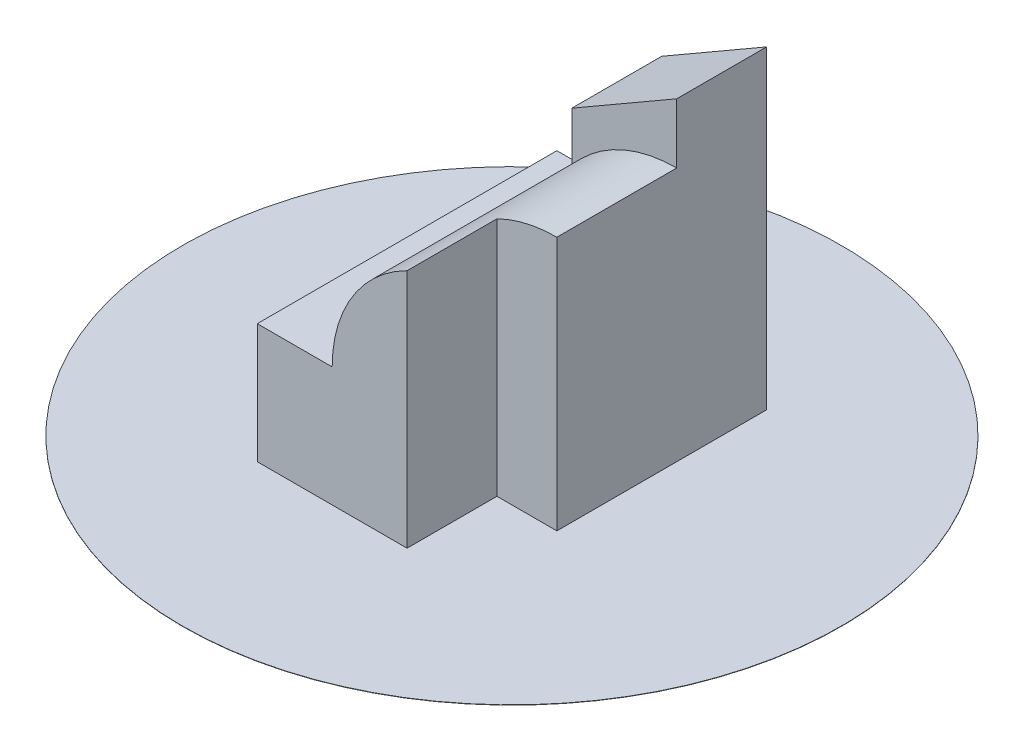
from build123d import *

# Parameters (mm, degrees)
EXTRUDE1_DEPTH = 100
SKETCH2_W      = 35
SKETCH2_H      = 30
EXTRUDE2_DEPTH = 105
SKETCH3_W      = 20
SKETCH3_H      = 30
EXTRUDE3_DEPTH = 105
EXTRUDE4_DEPTH = 31
SKETCH5_R      = 110
EXTRUDE5_DEPTH = 0.1


with BuildPart() as part:
    # Sketch1 → Extrude1 (new body)
    with BuildSketch(Plane.XY):
        with BuildLine():
            Line((0, 0), (70, 0))
            Line((70, 0), (70, 85))
            ThreePointArc((70, 85), (38.180194847, 71.819805153), (25, 40))
            Line((25, 40), (0, 40))
            Line((0, 40), (0, 0))
        make_face()
    extrude(amount=-EXTRUDE1_DEPTH)

    # Sketch2 → Extrude2 (add)
    with BuildSketch(Plane(origin=(0, 0, 0), x_dir=(1, 0, 0), z_dir=(0, 1, 0))):
        with Locations((52.5, 85)):
            Rectangle(SKETCH2_W, SKETCH2_H)
    extrude(amount=EXTRUDE2_DEPTH)

    # Sketch3 → Extrude3 (cut)
    with BuildSketch(Plane(origin=(0, 0, 0), x_dir=(1, 0, 0), z_dir=(0, 1, 0))):
        with Locations((60, 15)):
            Rectangle(SKETCH3_W, SKETCH3_H)
    extrude(amount=EXTRUDE3_DEPTH, mode=Mode.SUBTRACT)

    # Sketch4 → Extrude4 (cut, through all)
    with BuildSketch(Plane.XY.offset(-70)):
        Polygon((70, 105), (35, 105), (35, 84.792740578), align=None)
    extrude(amount=-EXTRUDE4_DEPTH, mode=Mode.SUBTRACT)

    # Sketch5 → Extrude5 (add)
    with BuildSketch(Plane(origin=(0, 0, 0), x_dir=(1, 0, 0), z_dir=(0, 1, 0))):
        with Locations(Location((35, 50, 0), (0, 0, 270))):  # turned: the seam where the file's is
            Circle(SKETCH5_R)
    extrude(amount=EXTRUDE5_DEPTH)


solid = part.part
